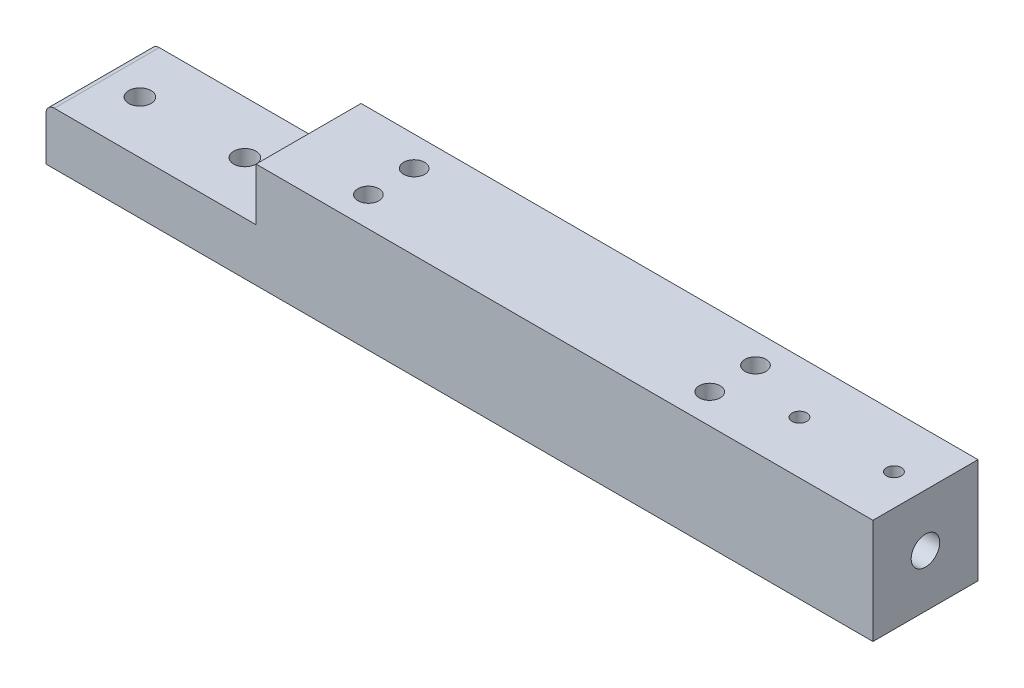
from build123d import *

# Parameters (mm, degrees)
SKETCH1_W                  = 100
SKETCH1_H                  = 12.7
BOSS_EXTRUDE1_DEPTH        = 6.35
SKETCH2_W                  = 25.4
SKETCH2_H                  = 6.35
CUT_EXTRUDE1_DEPTH         = 102.003032133
F_6_32_TAPPED_HOLE1_D      = 2.7051
F_8_32_TAPPED_HOLE1_D      = 3.4544
F_8_32_TAPPED_HOLE1_DEPTH  = 10
F_8_32_TAPPED_HOLE1_TIP    = 1.037806461
F_2_0_221_DIAMETER_HOLE1_D = 2.54
F_2_56_TAPPED_HOLE2_D      = 1.778
F_2_56_TAPPED_HOLE2_DEPTH  = 5
F_2_56_TAPPED_HOLE2_TIP    = 0.53416509
FILLET2_R                  = 1


with BuildPart() as part:
    # Sketch1 → Boss-Extrude1 (new, symmetric)
    with BuildSketch(Plane.XY):
        with Locations((50, 0)):
            Rectangle(SKETCH1_W, SKETCH1_H)
    extrude(amount=BOSS_EXTRUDE1_DEPTH, both=True)

    # Sketch2 → Cut-Extrude1 (cut, through all)
    with BuildSketch(Plane.XY.offset(6.35)):
        with Locations((12.7, 3.175)):
            Rectangle(SKETCH2_W, SKETCH2_H)
    extrude(amount=-CUT_EXTRUDE1_DEPTH, mode=Mode.SUBTRACT)

    # 6-32 Tapped Hole1 (through all)
    with Locations(Plane(origin=(0, 0, 0), x_dir=(-1, 0, 0), z_dir=(0, 1, 0))):
        with Locations((-17.7, 0), (-5, 0)):
            Hole(F_6_32_TAPPED_HOLE1_D / 2)

    # 8-32 Tapped Hole1
    with Locations(Plane(origin=(100, 0, 0), x_dir=(0, 0, -1), z_dir=(1, 0, 0))):
        with Locations((0, 0)):
            Hole(F_8_32_TAPPED_HOLE1_D / 2, depth=F_8_32_TAPPED_HOLE1_DEPTH)
            with Locations((0, 0, -(F_8_32_TAPPED_HOLE1_DEPTH + F_8_32_TAPPED_HOLE1_TIP / 2))):  # 118° drill point
                Cone(0, F_8_32_TAPPED_HOLE1_D / 2, F_8_32_TAPPED_HOLE1_TIP, mode=Mode.SUBTRACT)

    # 2 _0.221_ Diameter Hole1 (through all)
    with Locations(Plane(origin=(0, 6.35, 0), x_dir=(-1, 0, 0), z_dir=(0, 1, 0))):
        with Locations((-35.4, -2.7686), (-76.675, -2.7686), (-76.675, 2.7686), (-35.4, 2.7686)):
            Hole(F_2_0_221_DIAMETER_HOLE1_D / 2)

    # 2-56 Tapped Hole2
    with Locations(Plane(origin=(0, 6.35, 0), x_dir=(-1, 0, 0), z_dir=(0, 1, 0))):
        with Locations((-84.76, 0), (-96.19, 0)):
            Hole(F_2_56_TAPPED_HOLE2_D / 2, depth=F_2_56_TAPPED_HOLE2_DEPTH)
            with Locations((0, 0, -(F_2_56_TAPPED_HOLE2_DEPTH + F_2_56_TAPPED_HOLE2_TIP / 2))):  # 118° drill point
                Cone(0, F_2_56_TAPPED_HOLE2_D / 2, F_2_56_TAPPED_HOLE2_TIP, mode=Mode.SUBTRACT)

    # Fillet2
    fillet2_edges = [part.edges().sort_by_distance(p)[0] for p in [
        (0, 0, 0),
    ]]
    fillet(fillet2_edges, radius=FILLET2_R)


solid = part.part
